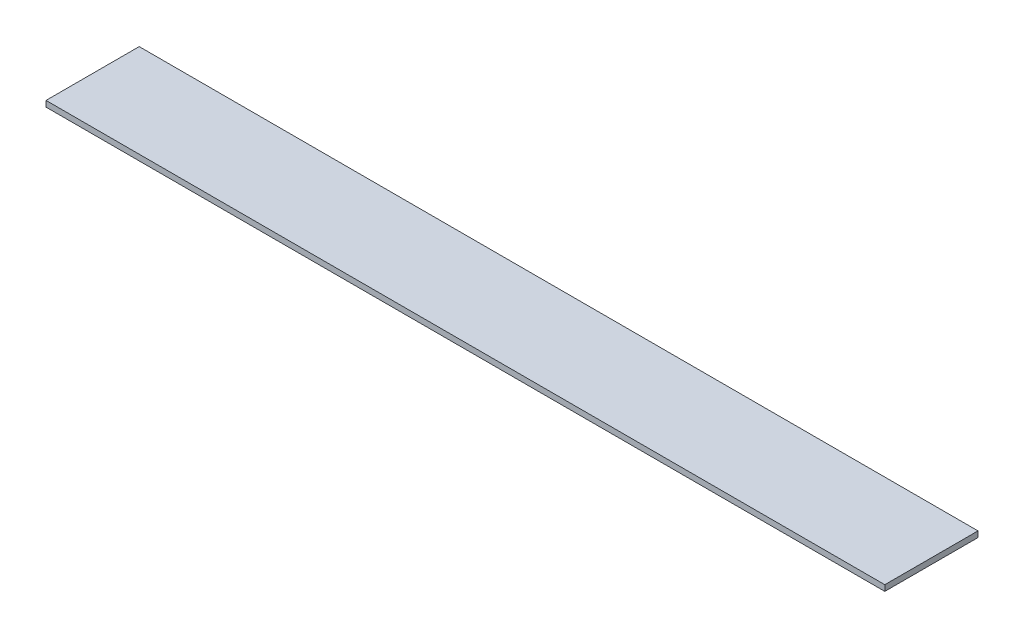
from build123d import *

# Parameters (mm, degrees)
SKETCH1_W           = 228.6
SKETCH1_H           = 25.4
BOSS_EXTRUDE1_DEPTH = 1.5875


with BuildPart() as part:
    # Sketch1 → Boss-Extrude1 (new body)
    with BuildSketch(Plane(origin=(0, 0, 0), x_dir=(1, 0, 0), z_dir=(0, 1, 0))):
        with Locations((114.3, 12.7)):
            Rectangle(SKETCH1_W, SKETCH1_H)
    extrude(amount=BOSS_EXTRUDE1_DEPTH)


solid = part.part
